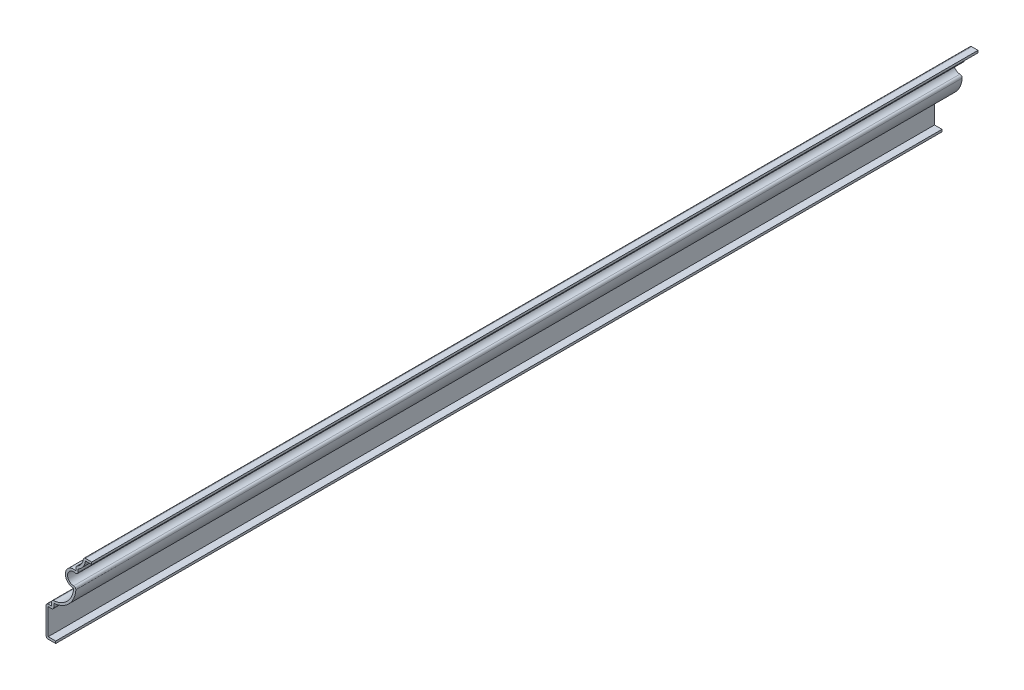
from build123d import *

# Parameters (mm, degrees)
EXTRUDE_THIN1_DEPTH = 508
FILLET1_R           = 1.27


with BuildPart() as part:
    # Sketch1 → Extrude-Thin1 (new body)
    with BuildSketch(Plane.XY):
        with BuildLine():
            Line((0, 0), (-5.55625, 0))
            Line((-5.55625, 0), (-5.55625, 17.4625))
            Line((-5.55625, 17.4625), (-2.38125, 17.4625))
            Line((-2.38125, 17.4625), (-2.38125, 20.6375))
            ThreePointArc((-2.38125, 20.6375), (6.3138456, 24.080863867), (10.293921042, 32.54375))
            ThreePointArc((10.293921042, 32.54375), (5.574731916, 37.947077782), (11.563921042, 41.896294254))
            Line((11.563921042, 41.896294254), (11.563921042, 44.277544254))
            ThreePointArc((11.563921042, 44.277544254), (14.734219617, 46.868057482), (15.875, 50.8))
            Line((15.875, 50.8), (20.6375, 50.8))
            Line((20.6375, 50.8), (20.6375, 49.53))
            Line((20.6375, 49.53), (17.066657415, 49.53))
            ThreePointArc((17.066657415, 49.53), (15.675566735, 45.99394981), (12.833921042, 43.471285746))
            Line((12.833921042, 43.471285746), (12.833921042, 39.703322433))
            ThreePointArc((12.833921042, 39.703322433), (6.885679815, 38.068777372), (11.570295001, 34.055338472))
            ThreePointArc((11.570295001, 34.055338472), (8.174933988, 24.187206037), (-1.11125, 19.425347039))
            Line((-1.11125, 19.425347039), (-1.11125, 16.1925))
            Line((-1.11125, 16.1925), (-4.28625, 16.1925))
            Line((-4.28625, 16.1925), (-4.28625, 1.27))
            Line((-4.28625, 1.27), (0, 1.27))
            Line((0, 1.27), (0, 0))
        make_face()
    extrude(amount=-EXTRUDE_THIN1_DEPTH)

    # Fillet1
    fillet1_edges = [part.edges().sort_by_distance(p)[0] for p in [
        (12.833921042, 39.703322433, -254),
        (11.570295001, 34.055338472, -254),
        (-1.11125, 16.1925, -254),
        (-5.55625, 0, -254),
        (-5.55625, 17.4625, -254),
        (-2.38125, 20.6375, -254),
        (11.563921042, 44.277544254, -254),
        (15.875, 50.8, -254),
    ]]
    fillet(fillet1_edges, radius=FILLET1_R)


solid = part.part
